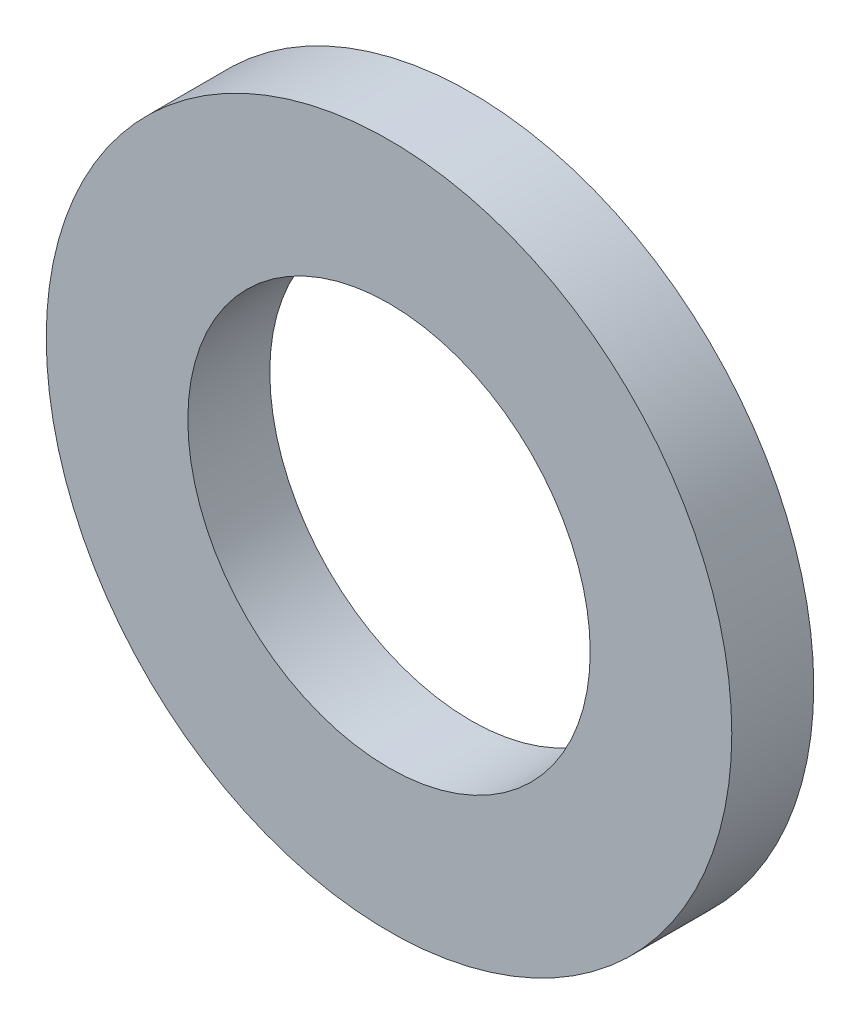
from build123d import *

# Parameters (mm, degrees)
SKETCH1_R           = 4.6
SKETCH1_R_2         = 2.7
BOSS_EXTRUDE1_DEPTH = 1.1


with BuildPart() as part:
    # Sketch1 → Boss-Extrude1 (new body)
    with BuildSketch(Plane.XY):
        Circle(SKETCH1_R)
        Circle(SKETCH1_R_2, mode=Mode.SUBTRACT)
    extrude(amount=BOSS_EXTRUDE1_DEPTH)


solid = part.part
